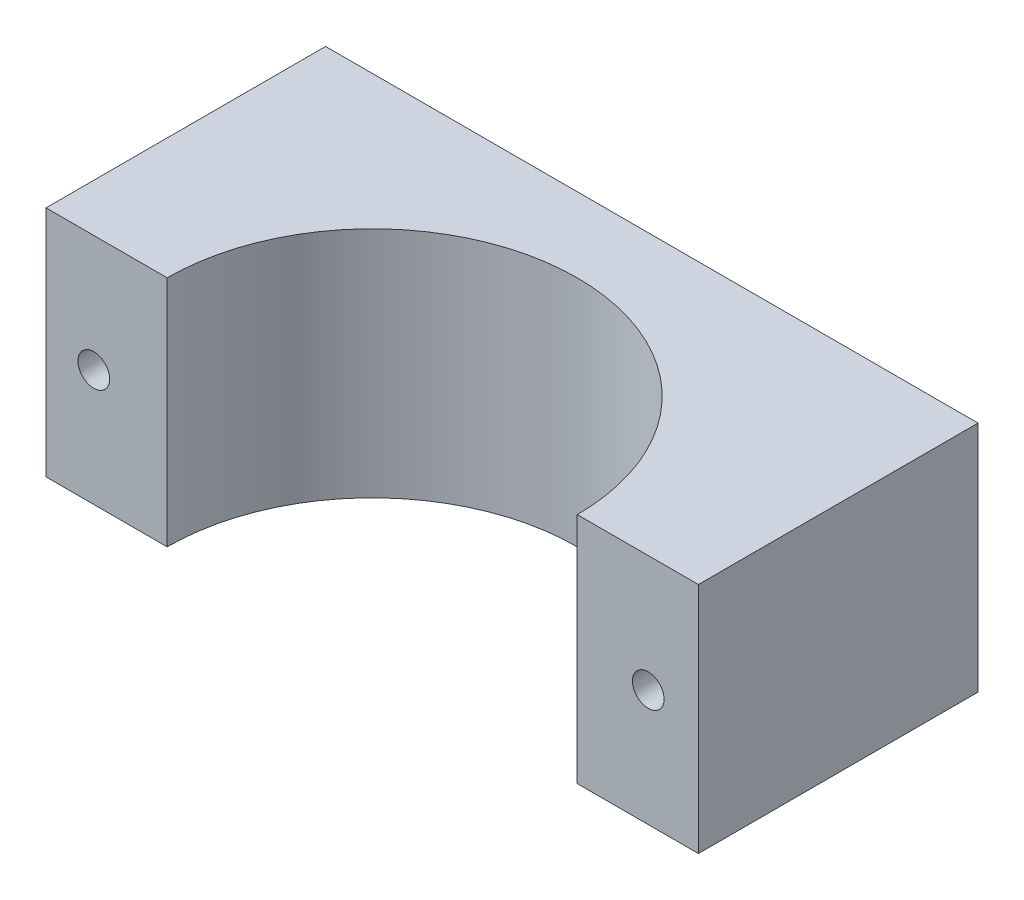
from build123d import *

# Parameters (mm, degrees)
BOSS_EXTRUDE1_DEPTH = 25
SKETCH3_R           = 1.7
BOSS_EXTRUDE2_DEPTH = 30
SKETCH3_2_R         = 1.7
CUT_EXTRUDE1_DEPTH  = 30


with BuildPart() as part:
    # Sketch1 → Boss-Extrude1 (new body)
    with BuildSketch(Plane(origin=(0, 0, 0), x_dir=(1, 0, 0), z_dir=(0, 1, 0))):
        with BuildLine():
            Line((-29.546079231, 30), (-29.546079231, 0))
            Line((-29.546079231, 0), (-16.546079231, 0))
            ThreePointArc((-16.546079231, 0), (5.453920769, 22), (27.453920769, 0))
            Line((27.453920769, 0), (40.453920769, 0))
            Line((40.453920769, 0), (40.453920769, 30))
            Line((40.453920769, 30), (-29.546079231, 30))
        make_face()
    extrude(amount=BOSS_EXTRUDE1_DEPTH)

    # Sketch3 → Boss-Extrude2 (add)
    with BuildSketch(Plane(origin=(0, 0, -30), x_dir=(-1, 0, 0), z_dir=(0, 0, -1))):
        with Locations((-35.073920769, 12.5)):
            Circle(SKETCH3_R)
        with Locations((24.416079231, 12.5)):
            Circle(SKETCH3_R)
    extrude(amount=-BOSS_EXTRUDE2_DEPTH)

    # Sketch3_2 → Cut-Extrude1 (cut)
    with BuildSketch(Plane(origin=(0, 0, -30), x_dir=(-1, 0, 0), z_dir=(0, 0, -1))):
        with Locations((-35.073920769, 12.5)):
            Circle(SKETCH3_2_R)
        with Locations((24.416079231, 12.5)):
            Circle(SKETCH3_2_R)
    extrude(amount=-CUT_EXTRUDE1_DEPTH, mode=Mode.SUBTRACT)


solid = part.part
